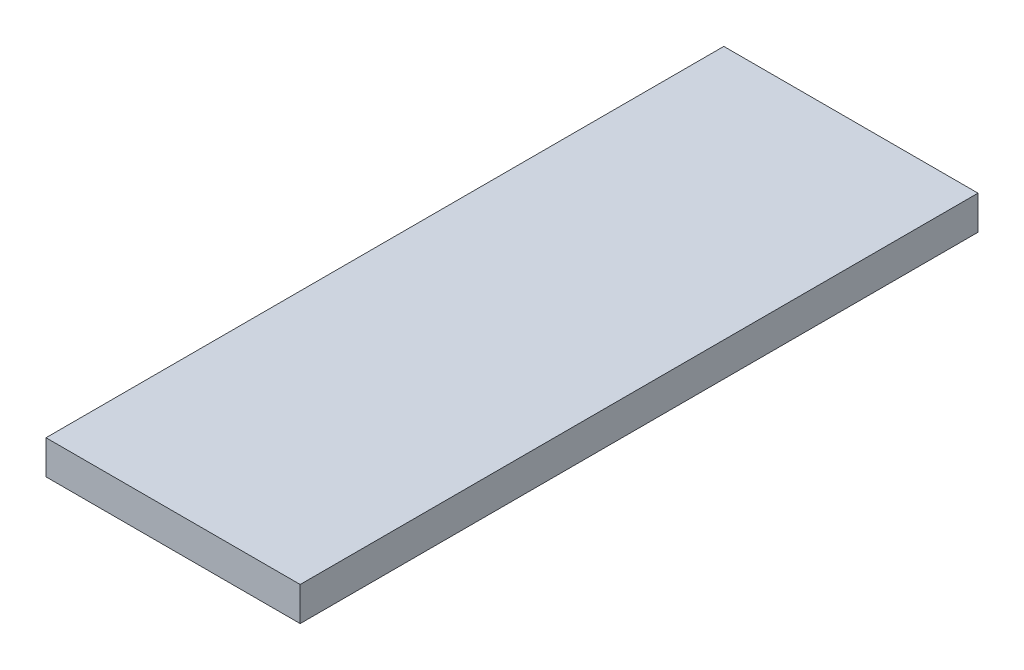
from build123d import *

# Parameters (mm, degrees)
SKETCH1_W           = 150
SKETCH1_H           = 400
BOSS_EXTRUDE1_DEPTH = 20


with BuildPart() as part:
    # Sketch1 → Boss-Extrude1 (new body)
    with BuildSketch(Plane(origin=(0, 0, 0), x_dir=(1, 0, 0), z_dir=(0, 1, 0))):
        Rectangle(SKETCH1_W, SKETCH1_H)
    extrude(amount=BOSS_EXTRUDE1_DEPTH)


solid = part.part
